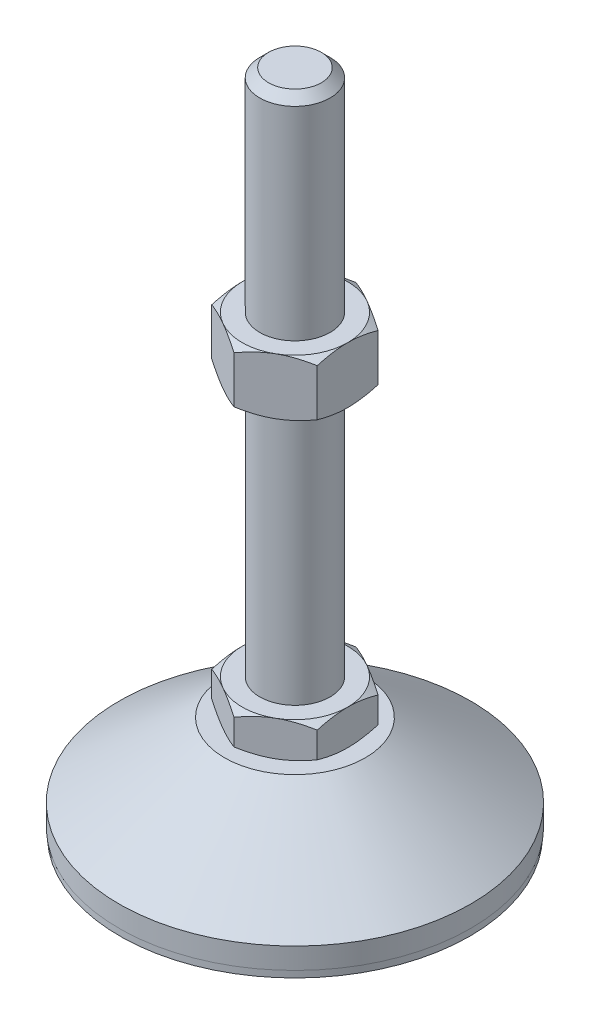
from build123d import *

# Parameters (mm, degrees)
EXTRUDE_1_DEPTH = 10
EXTRUDE_2_DEPTH = 16


with BuildPart() as part:
    # Эскиз1 → Повернуть1 (revolve)
    with BuildSketch(Plane.XY, mode=Mode.PRIVATE) as revolve_1_sk:
        Polygon((0, 0), (-49.8, 0), (-49.8, 2), (-50, 2), (-50, 8), (-20, 29), (-10, 29), (-10, 39), (-10, 186.5), (-7.5, 189), (0, 189), align=None)
    revolve(revolve_1_sk.sketch.rotate(Axis((0, 0, 0), (0, 1, 0)), 180), axis=Axis((0, 0, 0), (0, 1, 0)))  # turned: the seam where the file's is

    # Эскиз2 → Бобышка-Вытянуть1 (add)
    with BuildSketch(Plane(origin=(0, 29, 0), x_dir=(1, 0, 0), z_dir=(0, 1, 0))):
        Polygon((0, 17.320508076), (-15, 8.660254038), (-15, -8.660254038), (0, -17.320508076), (15, -8.660254038), (15, 8.660254038), align=None)
    extrude(amount=EXTRUDE_1_DEPTH)

    # Эскиз3 → Бобышка-Вытянуть2 (add)
    with BuildSketch(Plane(origin=(0, 112.75, 0), x_dir=(1, 0, 0), z_dir=(0, 1, 0))):
        Polygon((15, 8.660254038), (0, 17.320508076), (-15, 8.660254038), (-15, -8.660254038), (0, -17.320508076), (15, -8.660254038), align=None)
    extrude(amount=EXTRUDE_2_DEPTH)

    # Эскиз4 → Вырез-Повернуть2 (revolve, cut)
    with BuildSketch(Plane.XY, mode=Mode.PRIVATE) as cut_revolve_2_sk:
        Polygon((-28.856406461, 128.75), (-15, 128.75), (-28.856406461, 120.75), align=None)
        Polygon((-28.856406461, 112.75), (-28.856406461, 120.75), (-15, 112.75), align=None)
        Polygon((-23.660254038, 39), (-23.660254038, 34), (-15, 39), align=None)
        Polygon((-23.660254038, 34), (-23.660254038, 29), (-15, 29), align=None)
    revolve(cut_revolve_2_sk.sketch.rotate(Axis((0, 189, 0), (0, -1, 0)), 180), axis=Axis((0, 189, 0), (0, -1, 0)), mode=Mode.SUBTRACT)  # turned: the seam where the file's is


solid = part.part
